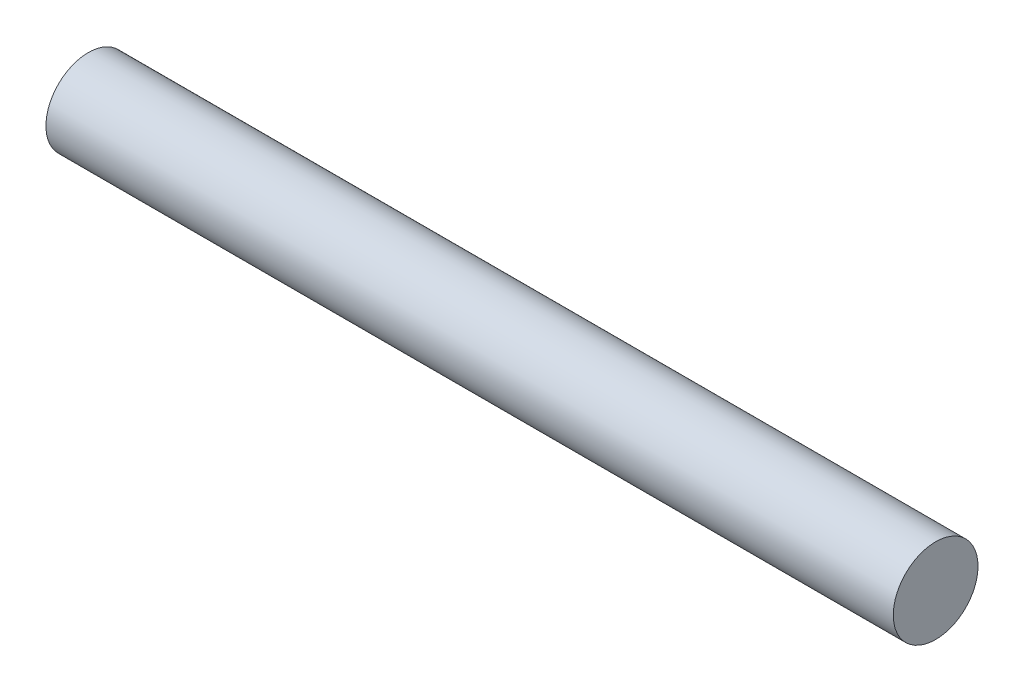
from build123d import *

# Parameters (mm, degrees)
SKETCH_1_R      = 4
EXTRUDE_1_DEPTH = 80


with BuildPart() as part:
    # 草图1 → 凸台-拉伸1 (new body)
    with BuildSketch(Plane(origin=(0, 0, 0), x_dir=(0, 0, -1), z_dir=(1, 0, 0))):
        Circle(SKETCH_1_R)
    extrude(amount=EXTRUDE_1_DEPTH)


solid = part.part
